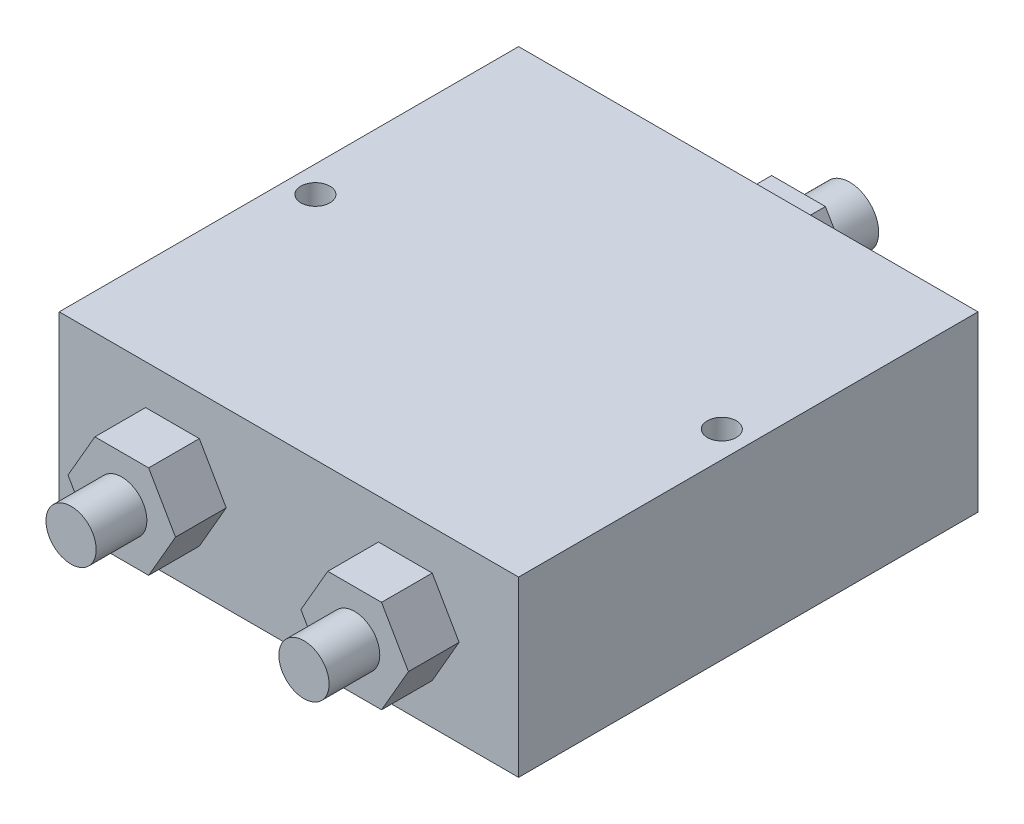
from build123d import *

# Parameters (mm, degrees)
SKETCH1_W           = 50.3
SKETCH1_H           = 50.3
BOSS_EXTRUDE1_DEPTH = 19
BOSS_EXTRUDE2_DEPTH = 5.55
BOSS_EXTRUDE3_DEPTH = 5.55
SKETCH5_R           = 3.175
BOSS_EXTRUDE4_DEPTH = 5.55
SKETCH7_R           = 2.75
BOSS_EXTRUDE5_DEPTH = 5.55
SKETCH8_R           = 1.59
CUT_EXTRUDE1_DEPTH  = 20


with BuildPart() as part:
    # Sketch1 → Boss-Extrude1 (new body)
    with BuildSketch(Plane(origin=(0, 0, 0), x_dir=(1, 0, 0), z_dir=(0, 1, 0))):
        Rectangle(SKETCH1_W, SKETCH1_H)
    extrude(amount=BOSS_EXTRUDE1_DEPTH)

    # Sketch2 → Boss-Extrude2 (add)
    with BuildSketch(Plane.XY.offset(25.15)):
        Polygon((-15.692878403, 14.649004006), (-18.635756806, 9.551789092), (-15.692878403, 4.454574178), (-9.807121597, 4.454574178), (-6.864243194, 9.551789092), (-9.807121597, 14.649004006), align=None)
        Polygon((18.635756806, 9.551789092), (15.692878403, 4.454574178), (9.807121597, 4.454574178), (6.864243194, 9.551789092), (9.807121597, 14.649004006), (15.692878403, 14.649004006), align=None)
    extrude(amount=BOSS_EXTRUDE2_DEPTH)

    # Sketch4 → Boss-Extrude3 (add)
    with BuildSketch(Plane(origin=(0, 0, -25.15), x_dir=(-1, 0, 0), z_dir=(0, 0, -1))):
        Polygon((-5.835508644, 9.984378867), (-2.892754322, 4.887378867), (2.992754322, 4.887378867), (5.935508644, 9.984378867), (2.992754322, 15.081378867), (-2.892754322, 15.081378867), align=None)
    extrude(amount=BOSS_EXTRUDE3_DEPTH)

    # Sketch5 → Boss-Extrude4 (add)
    with BuildSketch(Plane(origin=(0, 0, -30.7), x_dir=(-1, 0, 0), z_dir=(0, 0, -1))):
        with Locations((0, 9.996378867)):
            Circle(SKETCH5_R)
    extrude(amount=BOSS_EXTRUDE4_DEPTH)

    # Sketch7 → Boss-Extrude5 (add)
    with BuildSketch(Plane.XY.offset(30.7)):
        with Locations((-12.750756806, 9.564004006)):
            Circle(SKETCH7_R)
        with Locations((12.750756806, 9.564004006)):
            Circle(SKETCH7_R)
    extrude(amount=BOSS_EXTRUDE5_DEPTH)

    # Sketch8 → Cut-Extrude1 (cut, through all)
    with BuildSketch(Plane(origin=(0, 19, 0), x_dir=(1, 0, 0), z_dir=(0, 1, 0))):
        with Locations((-22.25, 0)):
            Circle(SKETCH8_R)
        with Locations((22.25, 0)):
            Circle(SKETCH8_R)
    extrude(amount=-CUT_EXTRUDE1_DEPTH, mode=Mode.SUBTRACT)


solid = part.part
